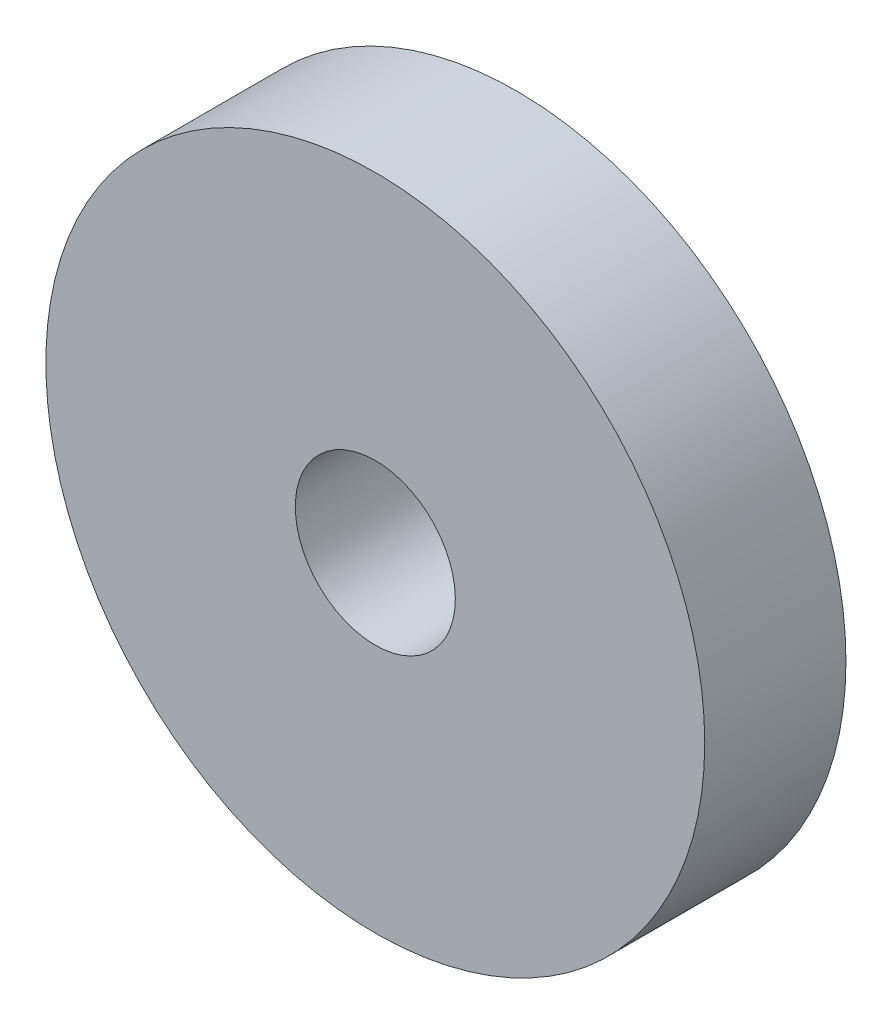
from build123d import *

# Parameters (mm, degrees)
SKETCH1_R           = 7
BOSS_EXTRUDE1_DEPTH = 3
SKETCH2_R           = 1.7
CUT_EXTRUDE1_DEPTH  = 3


with BuildPart() as part:
    # Sketch1 → Boss-Extrude1 (new body)
    with BuildSketch(Plane.XY):
        Circle(SKETCH1_R)
    extrude(amount=BOSS_EXTRUDE1_DEPTH)

    # Sketch2 → Cut-Extrude1 (cut)
    with BuildSketch(Plane.XY.offset(3)):
        Circle(SKETCH2_R)
    extrude(amount=-CUT_EXTRUDE1_DEPTH, mode=Mode.SUBTRACT)


solid = part.part
